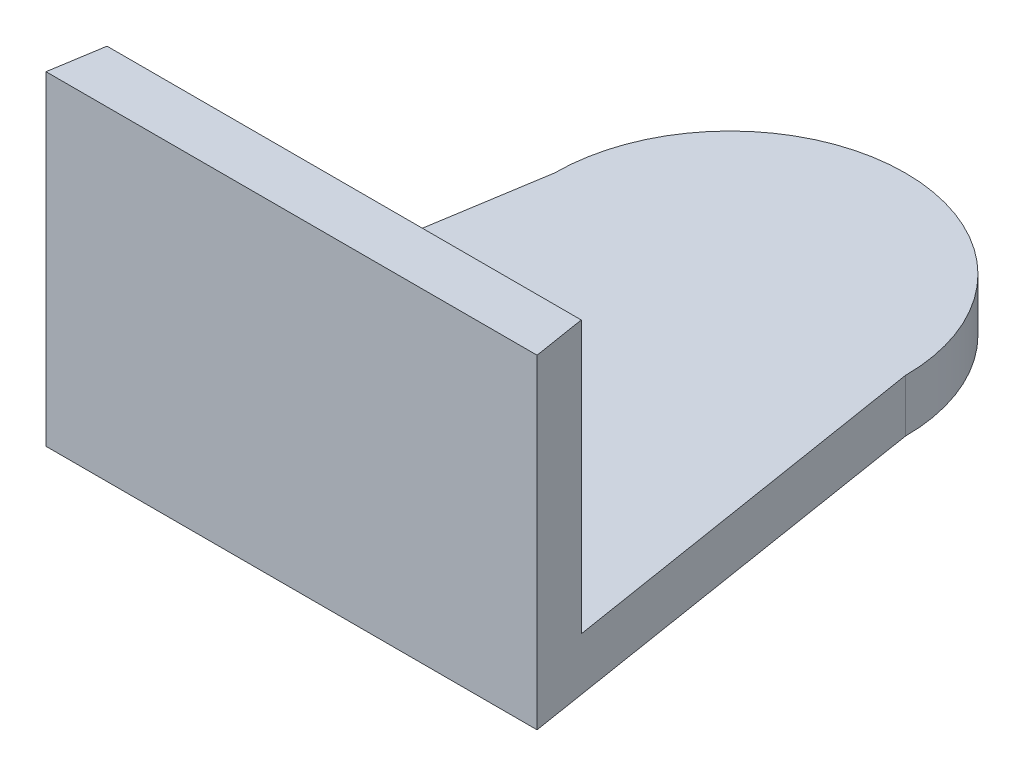
from build123d import *

# Parameters (mm, degrees)
BOSS_EXTRUDE1_DEPTH = 3
BOSS_EXTRUDE2_DEPTH = 15.5


with BuildPart() as part:
    # Sketch1 → Boss-Extrude1 (new body)
    with BuildSketch(Plane(origin=(0, 0, 0), x_dir=(1, 0, 0), z_dir=(0, 1, 0))):
        with BuildLine():
            Line((-10, 0), (-14, -25))
            Line((-14, -25), (14, -25))
            Line((14, -25), (10, 0))
            ThreePointArc((10, 0), (0, 10), (-10, 0))
        make_face()
    extrude(amount=BOSS_EXTRUDE1_DEPTH)

    # Sketch5 → Boss-Extrude2 (add)
    with BuildSketch(Plane(origin=(0, 3, 0), x_dir=(1, 0, 0), z_dir=(0, 1, 0))):
        Polygon((-13.52, -22), (13.52, -22), (14, -25), (-14, -25), align=None)
    extrude(amount=BOSS_EXTRUDE2_DEPTH)


solid = part.part
